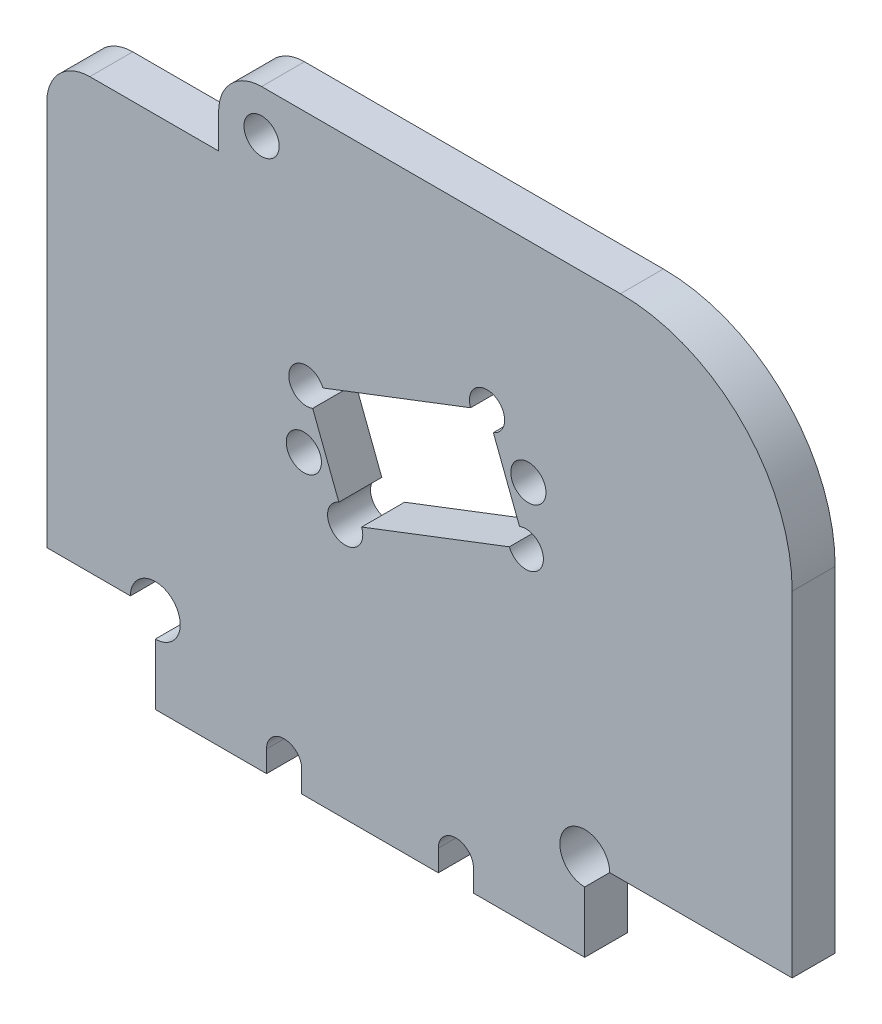
from build123d import *

# Parameters (mm, degrees)
SCHIZZO1_R                   = 2.5
SCHIZZO1_R_2                 = 2.05
ESTRUSIONE_ESTRUSIONE1_DEPTH = 5
SCHIZZO2_R                   = 2.05
TAGLIO_ESTRUSIONE1_DEPTH     = 6
CROQUIS1_W                   = 24.155603231
CROQUIS1_H                   = 18.627416998
CORTAR_EXTRUIR1_DEPTH        = 10
FILLET1_R                    = 5
CUT_EXTRUDE1_REACH           = 7
SKETCH1_R                    = 2.899137803
CUT_EXTRUDE2_REACH           = 7
SKETCH2_R                    = 2.05


with BuildPart() as part:
    # Schizzo1 → Estrusione-Estrusione1 (new body)
    with BuildSketch(Plane.XY):
        with BuildLine():
            Line((39.155603231, -41.372583002), (-35, -41.372583002))
            Line((-35, -41.372583002), (-35, -31.372583002))
            Line((-35, -31.372583002), (-47.627416998, -31.372583002))
            Line((-47.627416998, -31.372583002), (-47.627416998, 18.627416998))
            Line((-47.627416998, 18.627416998), (-27.627416998, 18.627416998))
            Line((-27.627416998, 18.627416998), (-27.627416998, 22.627416998))
            ThreePointArc((-27.627416998, 22.627416998), (-26.162950904, 26.162950904), (-22.627416998, 27.627416998))
            Line((-22.627416998, 27.627416998), (19.155603231, 27.627416998))
            ThreePointArc((19.155603231, 27.627416998), (33.297738855, 21.769552622), (39.155603231, 7.627416998))
            Line((39.155603231, 7.627416998), (39.155603231, -41.372583002))
        make_face()
        Circle(SCHIZZO1_R, mode=Mode.SUBTRACT)
        with Locations((-20, -38.872583002)):
            Circle(SCHIZZO1_R_2, mode=Mode.SUBTRACT)
        with Locations((0, -38.872583002)):
            Circle(SCHIZZO1_R_2, mode=Mode.SUBTRACT)
        with Locations((-22.627416998, 22.627416998)):
            Circle(SCHIZZO1_R_2, mode=Mode.SUBTRACT)
    extrude(amount=ESTRUSIONE_ESTRUSIONE1_DEPTH)

    # Schizzo2 → Taglio-Estrusione1 (cut, through all)
    with BuildSketch(Plane.XY.offset(5)):
        with Locations((-17.707593382, -6.797308246)):
            Circle(SCHIZZO2_R)
        with Locations((8.435926092, 3.238248629)):
            Circle(SCHIZZO2_R)
        Polygon((-12.894665672, -11.698011855), (8.138901337, -3.623981952), (3.623465173, 8.139131422), (-17.410101836, 0.065101519), align=None)
    extrude(amount=-TAGLIO_ESTRUSIONE1_DEPTH, mode=Mode.SUBTRACT)

    # Croquis1 → Cortar-Extruir1 (cut)
    with BuildSketch(Plane(origin=(0, 0, 0), x_dir=(-1, 0, 0), z_dir=(0, 0, -1))):
        with Locations((-27.077801616, -40.686291501)):
            Rectangle(CROQUIS1_W, CROQUIS1_H)
    extrude(amount=-CORTAR_EXTRUIR1_DEPTH, mode=Mode.SUBTRACT)

    # Fillet1
    fillet1_edges = [part.edges().sort_by_distance(p)[0] for p in [
        (-47.627416998, 18.627416998, 2.5),
    ]]
    fillet(fillet1_edges, radius=FILLET1_R)

    # Sketch1 → Cut-Extrude1 (cut, up to next)
    with BuildSketch(Plane.XY.offset(5), mode=Mode.PRIVATE) as cut_extrude1_sk1:
        with Locations((-35, -31.372583002)):
            Circle(SKETCH1_R)
    cut_extrude1_tool1 = extrude(cut_extrude1_sk1.sketch, amount=-CUT_EXTRUDE1_REACH, mode=Mode.PRIVATE) & part.part
    add(cut_extrude1_tool1.solids().sort_by_distance((-35, -31.372583, 5))[0], mode=Mode.SUBTRACT)
    # Sketch1 → Cut-Extrude1 (cut, up to next)
    with BuildSketch(Plane.XY.offset(5), mode=Mode.PRIVATE) as cut_extrude1_sk2:
        with Locations((15, -31.372583002)):
            Circle(SKETCH1_R)
    cut_extrude1_tool2 = extrude(cut_extrude1_sk2.sketch, amount=-CUT_EXTRUDE1_REACH, mode=Mode.PRIVATE) & part.part
    add(cut_extrude1_tool2.solids().sort_by_distance((15, -31.372583, 5))[0], mode=Mode.SUBTRACT)
    # Sketch1 → Cut-Extrude1 (cut, up to next)
    with BuildSketch(Plane.XY.offset(5), mode=Mode.PRIVATE) as cut_extrude1_sk3:
        with BuildLine():
            Line((-17.95, -38.872583002), (-17.95, -41.372583002))
            ThreePointArc((-17.95, -41.372583002), (-20, -43.422583002), (-22.05, -41.372583002))
            Line((-22.05, -41.372583002), (-22.05, -38.872583002))
            ThreePointArc((-22.05, -38.872583002), (-20, -36.822583002), (-17.95, -38.872583002))
        make_face()
    cut_extrude1_tool3 = extrude(cut_extrude1_sk3.sketch, amount=-CUT_EXTRUDE1_REACH, mode=Mode.PRIVATE) & part.part
    add(cut_extrude1_tool3.solids().sort_by_distance((-20, -40.122583, 5))[0], mode=Mode.SUBTRACT)
    # Sketch1 → Cut-Extrude1 (cut, up to next)
    with BuildSketch(Plane.XY.offset(5), mode=Mode.PRIVATE) as cut_extrude1_sk4:
        with BuildLine():
            Line((2.05, -38.872583002), (2.05, -41.372583002))
            ThreePointArc((2.05, -41.372583002), (0, -43.422583002), (-2.05, -41.372583002))
            Line((-2.05, -41.372583002), (-2.05, -38.872583002))
            ThreePointArc((-2.05, -38.872583002), (0, -36.822583002), (2.05, -38.872583002))
        make_face()
    cut_extrude1_tool4 = extrude(cut_extrude1_sk4.sketch, amount=-CUT_EXTRUDE1_REACH, mode=Mode.PRIVATE) & part.part
    add(cut_extrude1_tool4.solids().sort_by_distance((0, -40.122583, 5))[0], mode=Mode.SUBTRACT)

    # Sketch2 → Cut-Extrude2 (cut, up to next)
    with BuildSketch(Plane.XY.offset(5), mode=Mode.PRIVATE) as cut_extrude2_sk1:
        with Locations((-12.894665672, -11.698011855)):
            Circle(SKETCH2_R)
    cut_extrude2_tool1 = extrude(cut_extrude2_sk1.sketch, amount=-CUT_EXTRUDE2_REACH, mode=Mode.PRIVATE) & part.part
    add(cut_extrude2_tool1.solids().sort_by_distance((-12.894666, -11.698012, 5))[0], mode=Mode.SUBTRACT)
    # Sketch2 → Cut-Extrude2 (cut, up to next)
    with BuildSketch(Plane.XY.offset(5), mode=Mode.PRIVATE) as cut_extrude2_sk2:
        with Locations((8.138901337, -3.623981952)):
            Circle(SKETCH2_R)
    cut_extrude2_tool2 = extrude(cut_extrude2_sk2.sketch, amount=-CUT_EXTRUDE2_REACH, mode=Mode.PRIVATE) & part.part
    add(cut_extrude2_tool2.solids().sort_by_distance((8.138901, -3.623982, 5))[0], mode=Mode.SUBTRACT)
    # Sketch2 → Cut-Extrude2 (cut, up to next)
    with BuildSketch(Plane.XY.offset(5), mode=Mode.PRIVATE) as cut_extrude2_sk3:
        with Locations((3.623465173, 8.139131422)):
            Circle(SKETCH2_R)
    cut_extrude2_tool3 = extrude(cut_extrude2_sk3.sketch, amount=-CUT_EXTRUDE2_REACH, mode=Mode.PRIVATE) & part.part
    add(cut_extrude2_tool3.solids().sort_by_distance((3.623465, 8.139131, 5))[0], mode=Mode.SUBTRACT)
    # Sketch2 → Cut-Extrude2 (cut, up to next)
    with BuildSketch(Plane.XY.offset(5), mode=Mode.PRIVATE) as cut_extrude2_sk4:
        with Locations((-17.410101836, 0.065101519)):
            Circle(SKETCH2_R)
    cut_extrude2_tool4 = extrude(cut_extrude2_sk4.sketch, amount=-CUT_EXTRUDE2_REACH, mode=Mode.PRIVATE) & part.part
    add(cut_extrude2_tool4.solids().sort_by_distance((-17.410102, 0.065102, 5))[0], mode=Mode.SUBTRACT)


solid = part.part
